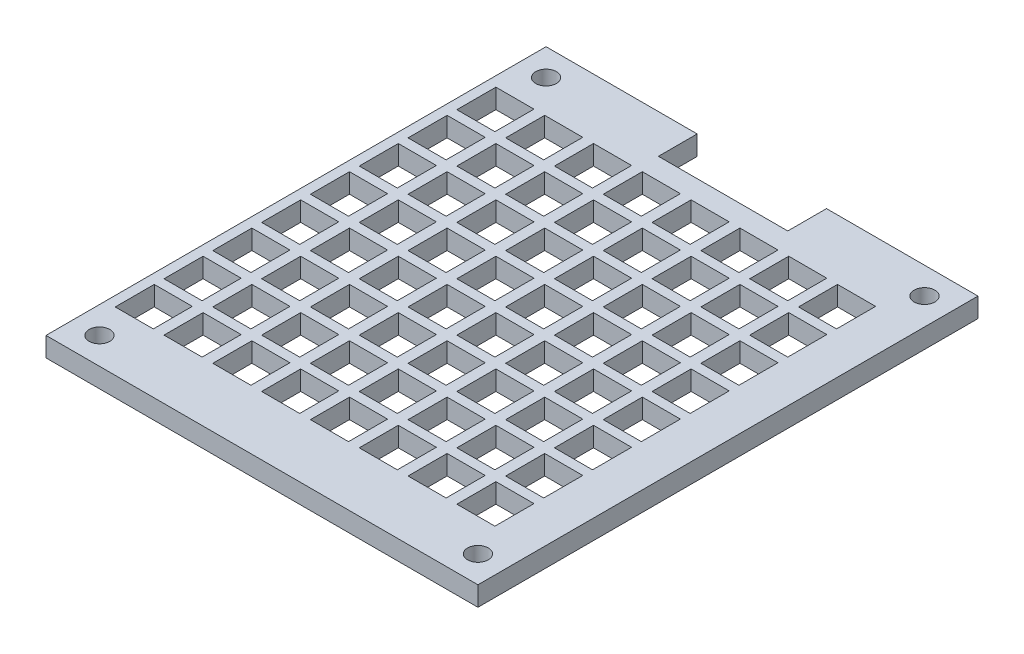
from build123d import *

# Parameters (mm, degrees)
SKETCH1_R            = 1.3462
BOSS_EXTRUDE1_DEPTH  = 2.54
SKETCH2_W            = 4.953
SKETCH2_H            = 5.08
CUT_EXTRUDE1_DEPTH   = 3.54
LPATTERN1_COUNT      = 8
LPATTERN1_PITCH      = 6.35
LPATTERN1_COUNT_DIR2 = 8
LPATTERN1_PITCH_DIR2 = 6.35


with BuildPart() as part:
    # Sketch1 → Boss-Extrude1 (new body)
    with BuildSketch(Plane(origin=(0, 0, 0), x_dir=(1, 0, 0), z_dir=(0, 1, 0))):
        Polygon((56.1975, 65.0621), (36.4871, 65.0621), (36.4871, 60.0202), (19.6596, 60.0202), (19.6596, 65.0621), (0, 65.0621), (0, 0), (56.1975, 0), align=None)
        with Locations((3.4798, 3.4798)):
            Circle(SKETCH1_R, mode=Mode.SUBTRACT)
        with Locations((52.7177, 3.4798)):
            Circle(SKETCH1_R, mode=Mode.SUBTRACT)
        with Locations((3.4798, 61.5823)):
            Circle(SKETCH1_R, mode=Mode.SUBTRACT)
        with Locations((52.7177, 61.5823)):
            Circle(SKETCH1_R, mode=Mode.SUBTRACT)
    extrude(amount=BOSS_EXTRUDE1_DEPTH)

    # Sketch2 → Cut-Extrude1 (cut, through all)
    with BuildSketch(Plane(origin=(0, 2.54, 0), x_dir=(1, 0, 0), z_dir=(0, 1, 0))):
        with Locations((3.7719, 54.6989)):
            Rectangle(SKETCH2_W, SKETCH2_H)
    cut_extrude1 = extrude(amount=-CUT_EXTRUDE1_DEPTH, mode=Mode.SUBTRACT)

    # LPattern1: Cut-Extrude1 8 × 8
    with Locations(*[(i * LPATTERN1_PITCH, 0, j * LPATTERN1_PITCH_DIR2) for i in range(LPATTERN1_COUNT) for j in range(LPATTERN1_COUNT_DIR2) if (i, j) != (0, 0)]):
        add(cut_extrude1, mode=Mode.SUBTRACT)


solid = part.part
